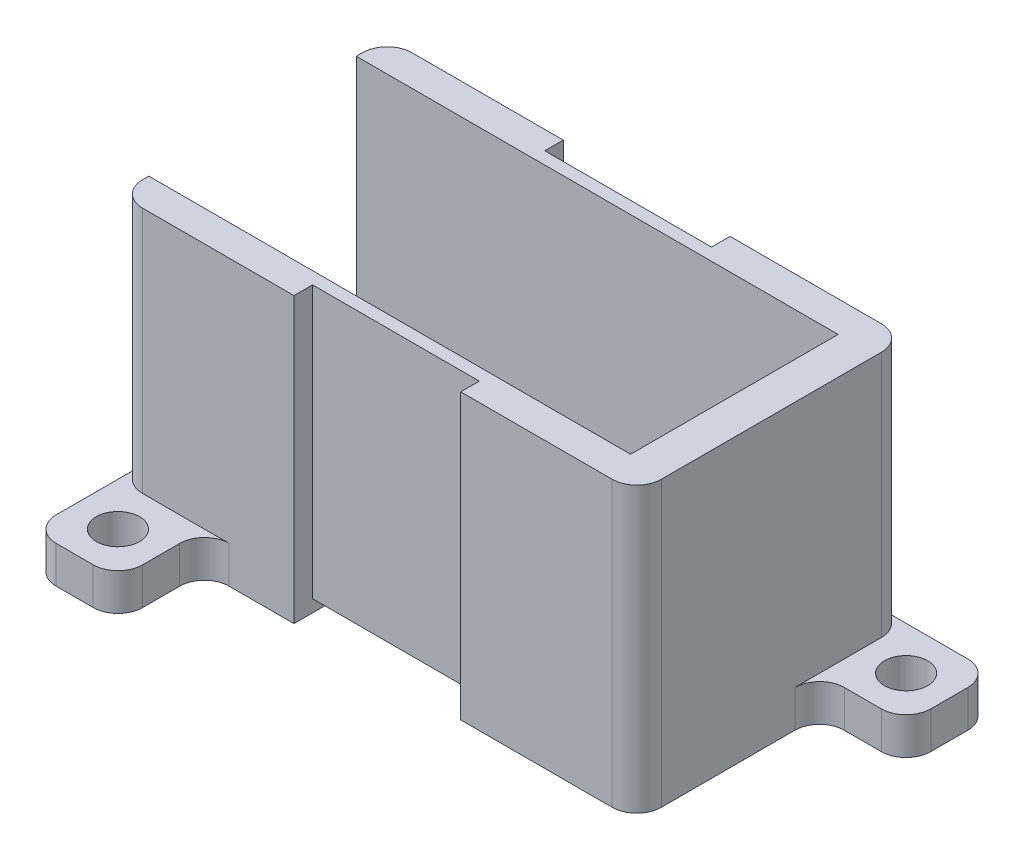
from build123d import *

# Parameters (mm, degrees)
SKETCH1_W               = 3.5
SKETCH1_H               = 1
SKETCH1_H_2             = 1.5
SKETCH1_W_2             = 13.5
SKETCH1_W_3             = 11.25
SKETCH1_H_3             = 16.8
BOSS_EXTRUDE1_DEPTH     = 3
BOSS_EXTRUDE2_START     = 3
SKETCH1_5_W             = 3.5
SKETCH1_5_H             = 1
SKETCH1_5_H_2           = 1.5
SKETCH1_5_W_2           = 13.5
BOSS_EXTRUDE2_DEPTH     = 20
SKETCH1_7_W             = 13.5
SKETCH1_7_H             = 1.5
CUT_EXTRUDE1_DEPTH      = 24
CUT_EXTRUDE1_DEPTH_BACK = 1
SKETCH1_8_W             = 13.5
SKETCH1_8_H             = 16.8
SKETCH1_8_H_2           = 1.5
SKETCH1_8_H_3           = 1
CUT_EXTRUDE2_DEPTH      = 1
SKETCH2_W               = 7
SKETCH2_H               = 7
SKETCH2_R               = 1.75
BOSS_EXTRUDE3_DEPTH     = 3
FILLET1_R               = 2


with BuildPart() as part:
    # Sketch1 → Boss-Extrude1 (new body)
    with BuildSketch(Plane(origin=(0, 0, 0), x_dir=(1, 0, 0), z_dir=(0, 1, 0))):
        Polygon((-5.5, 11.1), (5.25, 11.1), (5.25, 27.9), (-9, 27.9), (-9, 11.1), align=None)
        Polygon((-9, 27.9), (5.25, 27.9), (5.25, 28.9), (5.25, 30.4), (-2, 30.4), (-9, 30.4), align=None)
        Polygon((-5.5, 8.6), (5.25, 8.6), (5.25, 10.1), (5.25, 11.1), (-5.5, 11.1), (-5.5, 9.6), align=None)
        with Locations((-7.25, 9.1)):
            Rectangle(SKETCH1_W, SKETCH1_H)
        with Locations((-7.25, 10.35)):
            Rectangle(SKETCH1_W, SKETCH1_H_2)
        with Locations((12, 10.6)):
            Rectangle(SKETCH1_W_2, SKETCH1_H)
        with Locations((12, 9.35)):
            Rectangle(SKETCH1_W_2, SKETCH1_H_2)
        Polygon((18.75, 10.1), (18.75, 8.6), (30, 8.6), (33, 8.6), (33, 11.1), (30, 11.1), (18.75, 11.1), align=None)
        Polygon((30, 11.1), (33, 11.1), (33, 30.4), (18.75, 30.4), (18.75, 28.9), (18.75, 27.9), (30, 27.9), align=None)
        with Locations((12, 28.4)):
            Rectangle(SKETCH1_W_2, SKETCH1_H)
        with Locations((12, 29.65)):
            Rectangle(SKETCH1_W_2, SKETCH1_H_2)
        with Locations((24.375, 19.5)):
            Rectangle(SKETCH1_W_3, SKETCH1_H_3)
        with Locations((12, 19.5)):
            Rectangle(SKETCH1_W_2, SKETCH1_H_3)
    extrude(amount=BOSS_EXTRUDE1_DEPTH)

    # Sketch1_5 → Boss-Extrude2 (add)
    with BuildSketch(Plane(origin=(0, 0, 0), x_dir=(1, 0, 0), z_dir=(0, 1, 0)).offset(BOSS_EXTRUDE2_START)):
        Polygon((-9, 27.9), (5.25, 27.9), (5.25, 28.9), (5.25, 30.4), (-2, 30.4), (-9, 30.4), align=None)
        Polygon((-5.5, 8.6), (5.25, 8.6), (5.25, 10.1), (5.25, 11.1), (-5.5, 11.1), (-5.5, 9.6), align=None)
        with Locations((-7.25, 9.1)):
            Rectangle(SKETCH1_5_W, SKETCH1_5_H)
        with Locations((-7.25, 10.35)):
            Rectangle(SKETCH1_5_W, SKETCH1_5_H_2)
        Polygon((18.75, 10.1), (18.75, 8.6), (30, 8.6), (33, 8.6), (33, 11.1), (30, 11.1), (18.75, 11.1), align=None)
        with Locations((12, 10.6)):
            Rectangle(SKETCH1_5_W_2, SKETCH1_5_H)
        Polygon((30, 11.1), (33, 11.1), (33, 30.4), (18.75, 30.4), (18.75, 28.9), (18.75, 27.9), (30, 27.9), align=None)
        with Locations((12, 28.4)):
            Rectangle(SKETCH1_5_W_2, SKETCH1_5_H)
    extrude(amount=BOSS_EXTRUDE2_DEPTH)

    # Sketch1_7 → Cut-Extrude1 (cut, two sides)
    with BuildSketch(Plane(origin=(0, 0, 0), x_dir=(1, 0, 0), z_dir=(0, 1, 0))) as cut_extrude1_sk:
        with Locations((12, 29.65)):
            Rectangle(SKETCH1_7_W, SKETCH1_7_H)
        with Locations((12, 9.35)):
            Rectangle(SKETCH1_7_W, SKETCH1_7_H)
    extrude(amount=CUT_EXTRUDE1_DEPTH, mode=Mode.SUBTRACT)
    extrude(cut_extrude1_sk.sketch, amount=-CUT_EXTRUDE1_DEPTH_BACK, mode=Mode.SUBTRACT)

    # Sketch1_8 → Cut-Extrude2 (cut)
    with BuildSketch(Plane(origin=(0, 0, 0), x_dir=(1, 0, 0), z_dir=(0, 1, 0))):
        with Locations((12, 19.5)):
            Rectangle(SKETCH1_8_W, SKETCH1_8_H)
        with Locations((12, 29.65)):
            Rectangle(SKETCH1_8_W, SKETCH1_8_H_2)
        with Locations((12, 28.4)):
            Rectangle(SKETCH1_8_W, SKETCH1_8_H_3)
        with Locations((12, 9.35)):
            Rectangle(SKETCH1_8_W, SKETCH1_8_H_2)
        with Locations((12, 10.6)):
            Rectangle(SKETCH1_8_W, SKETCH1_8_H_3)
    extrude(amount=CUT_EXTRUDE2_DEPTH, mode=Mode.SUBTRACT)

    # Sketch2 → Boss-Extrude3 (add)
    with BuildSketch(Plane(origin=(0, 0, 0), x_dir=(-1, 0, 0), z_dir=(0, 1, 0))):
        with Locations((5.5, -5.1)):
            Rectangle(SKETCH2_W, SKETCH2_H)
        with Locations((5.5, -5.1)):
            Circle(SKETCH2_R, mode=Mode.SUBTRACT)
        with Locations((-36.5, -26.9)):
            Rectangle(SKETCH2_W, SKETCH2_H)
        with Locations((-36.5, -26.9)):
            Circle(SKETCH2_R, mode=Mode.SUBTRACT)
    extrude(amount=BOSS_EXTRUDE3_DEPTH)

    # Fillet1
    fillet1_edges = [part.edges().sort_by_distance(p)[0] for p in [
        (33, 11.5, -8.6),
        (-9, 13, -8.6),
        (-9, 11.5, -30.4),
        (33, 13, -30.4),
        (-9, 1.5, -1.6),
        (-2, 1.5, -1.6),
        (-2, 1.5, -8.6),
        (33, 1.5, -23.4),
        (40, 1.5, -23.4),
        (40, 1.5, -30.4),
    ]]
    fillet(fillet1_edges, radius=FILLET1_R)


solid = part.part
